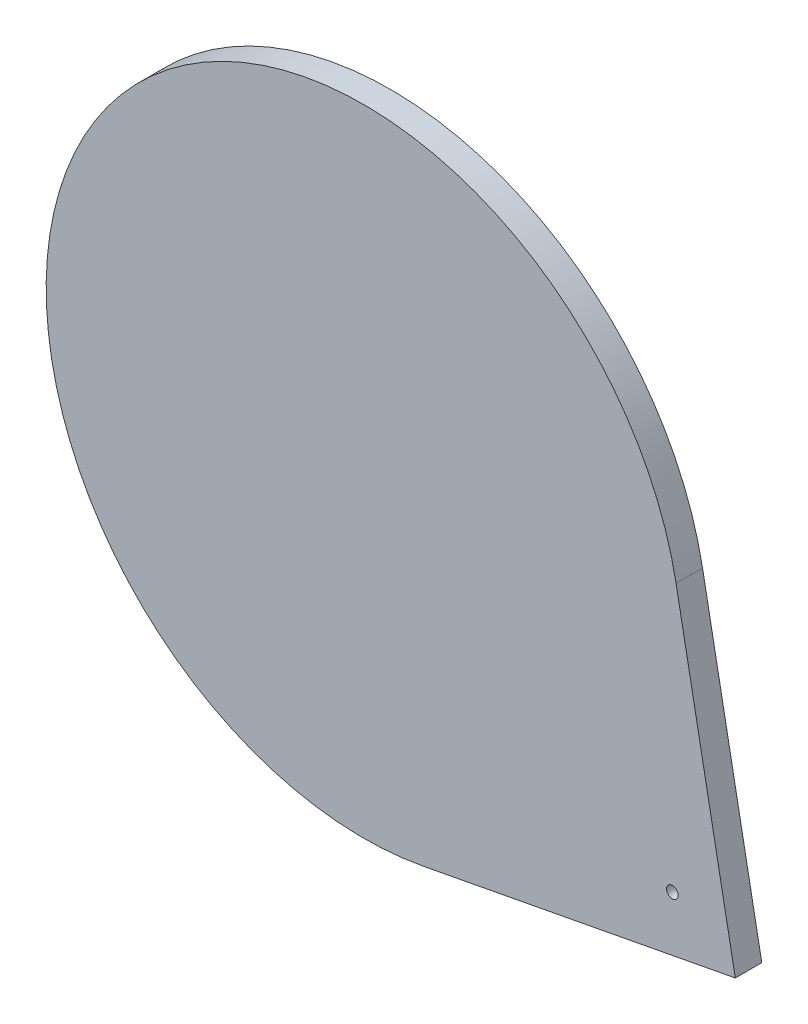
from build123d import *

# Parameters (mm, degrees)
SKETCH1_R           = 1.1
BOSS_EXTRUDE1_DEPTH = 5


with BuildPart() as part:
    # Sketch1 → Boss-Extrude1 (new body)
    with BuildSketch(Plane.XY):
        with BuildLine():
            Line((58.948050608, 11.186032786), (70.134083395, -47.762017822))
            Line((70.134083395, -47.762017822), (11.186032786, -58.948050608))
            ThreePointArc((11.186032786, -58.948050608), (-49.592285961, 33.772846685), (58.948050608, 11.186032786))
        make_face()
        with Locations((58.245885753, -39.666035381)):
            Circle(SKETCH1_R, mode=Mode.SUBTRACT)
    extrude(amount=BOSS_EXTRUDE1_DEPTH)


solid = part.part
